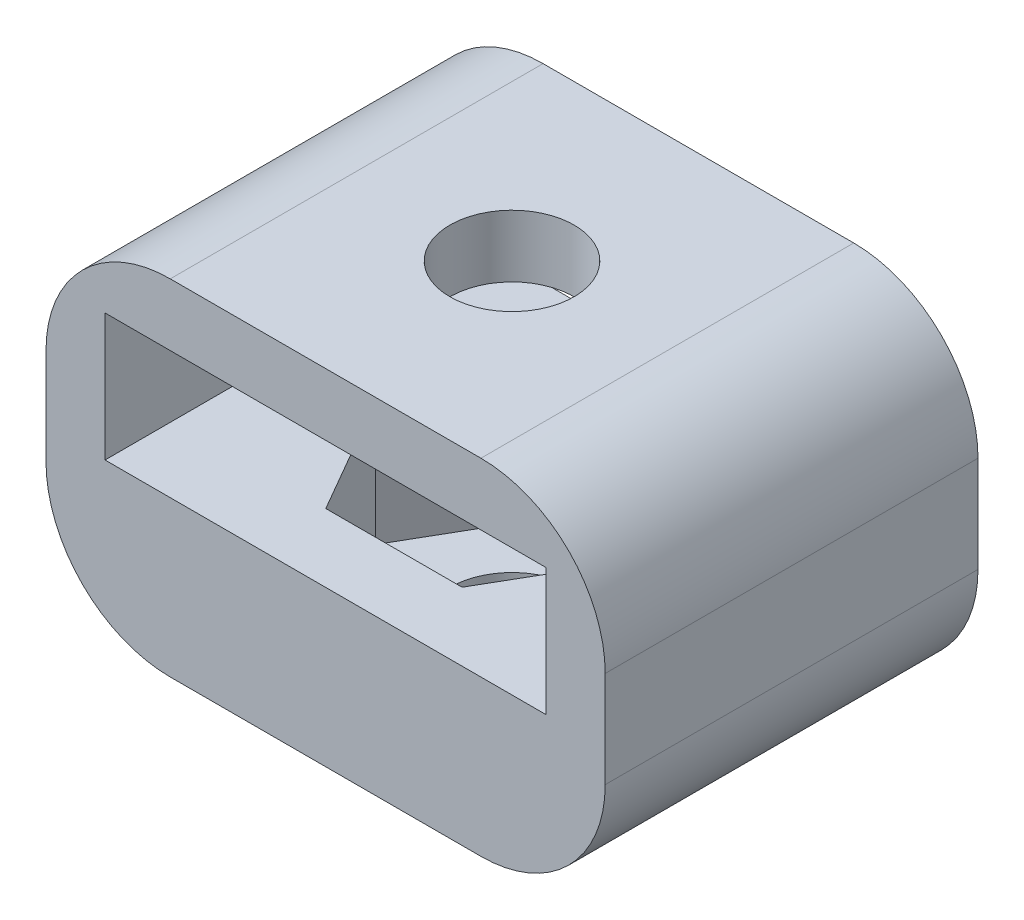
from build123d import *

# Parameters (mm, degrees)
SKETCH1_W           = 22.86
SKETCH1_H           = 15.24
BOSS_EXTRUDE1_DEPTH = 5.08
SKETCH3_W           = 2.413
SKETCH3_H           = 15.24
BOSS_EXTRUDE3_DEPTH = 5.207
SKETCH4_W           = 22.86
SKETCH4_H           = 15.24
SKETCH4_R           = 2.54
BOSS_EXTRUDE4_DEPTH = 2.54
SKETCH5_W           = 22.86
SKETCH5_H           = 15.24
SKETCH5_R           = 2.54
BOSS_EXTRUDE5_DEPTH = 1.27
FILLET1_R           = 5.08


with BuildPart() as part:
    # Sketch1 → Boss-Extrude1 (new body)
    with BuildSketch(Plane(origin=(0, 0, 0), x_dir=(1, 0, 0), z_dir=(0, 1, 0))):
        Rectangle(SKETCH1_W, SKETCH1_H)
        Polygon((5.572584798, 0), (2.786292399, 4.826), (-2.786292399, 4.826), (-5.572584798, 0), (-2.786292399, -4.826), (2.786292399, -4.826), align=None, mode=Mode.SUBTRACT)
    extrude(amount=BOSS_EXTRUDE1_DEPTH)

    # Sketch3 → Boss-Extrude3 (add)
    with BuildSketch(Plane(origin=(0, 5.08, 0), x_dir=(1, 0, 0), z_dir=(0, 1, 0))):
        with Locations((-10.2235, 0)):
            Rectangle(SKETCH3_W, SKETCH3_H)
        with Locations((10.2235, 0)):
            Rectangle(SKETCH3_W, SKETCH3_H)
    extrude(amount=BOSS_EXTRUDE3_DEPTH)

    # Sketch4 → Boss-Extrude4 (add)
    with BuildSketch(Plane(origin=(0, 10.287, 0), x_dir=(1, 0, 0), z_dir=(0, 1, 0))):
        Rectangle(SKETCH4_W, SKETCH4_H)
        Circle(SKETCH4_R, mode=Mode.SUBTRACT)
    extrude(amount=BOSS_EXTRUDE4_DEPTH)

    # Sketch5 → Boss-Extrude5 (add)
    with BuildSketch(Plane.XZ):
        Rectangle(SKETCH5_W, SKETCH5_H)
        Circle(SKETCH5_R, mode=Mode.SUBTRACT)
    extrude(amount=BOSS_EXTRUDE5_DEPTH)

    # Fillet1
    fillet1_edges = [part.edges().sort_by_distance(p)[0] for p in [
        (-11.43, 12.827, 0),
        (11.43, 12.827, 0),
        (-11.43, -1.27, 0),
        (11.43, -1.27, 0),
    ]]
    fillet(fillet1_edges, radius=FILLET1_R)


solid = part.part
